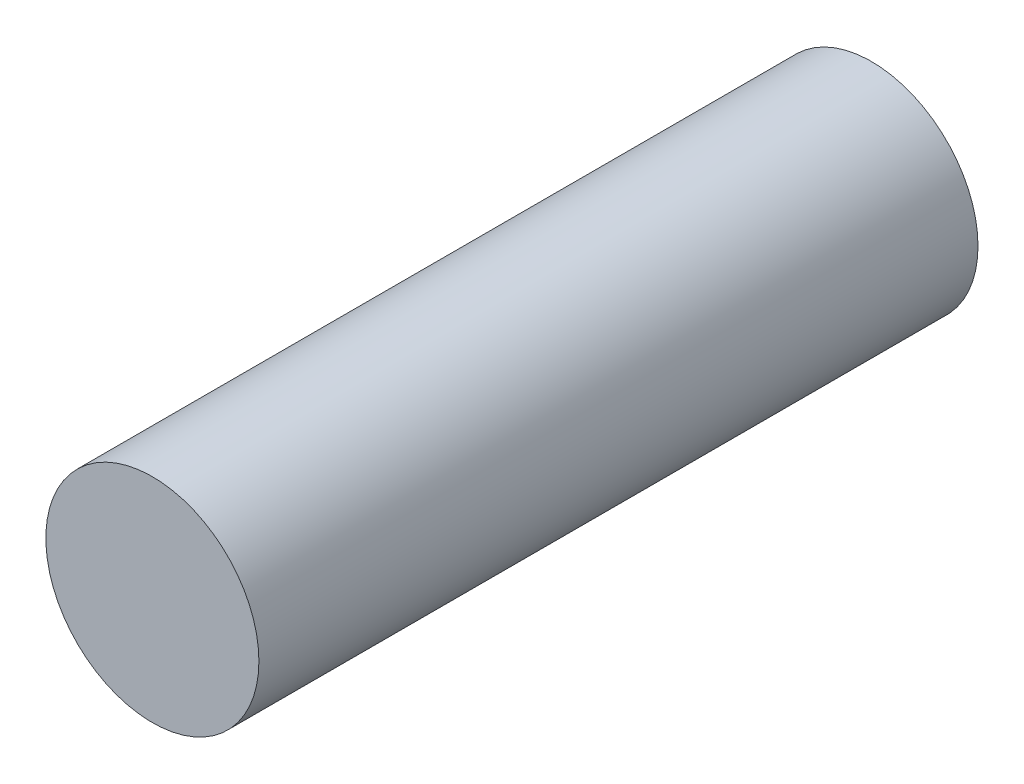
from build123d import *

# Parameters (mm, degrees)
SKETCH1_R           = 4
BOSS_EXTRUDE1_DEPTH = 27


with BuildPart() as part:
    # Sketch1 → Boss-Extrude1 (new body)
    with BuildSketch(Plane.XY):
        Circle(SKETCH1_R)
    extrude(amount=BOSS_EXTRUDE1_DEPTH)


solid = part.part
